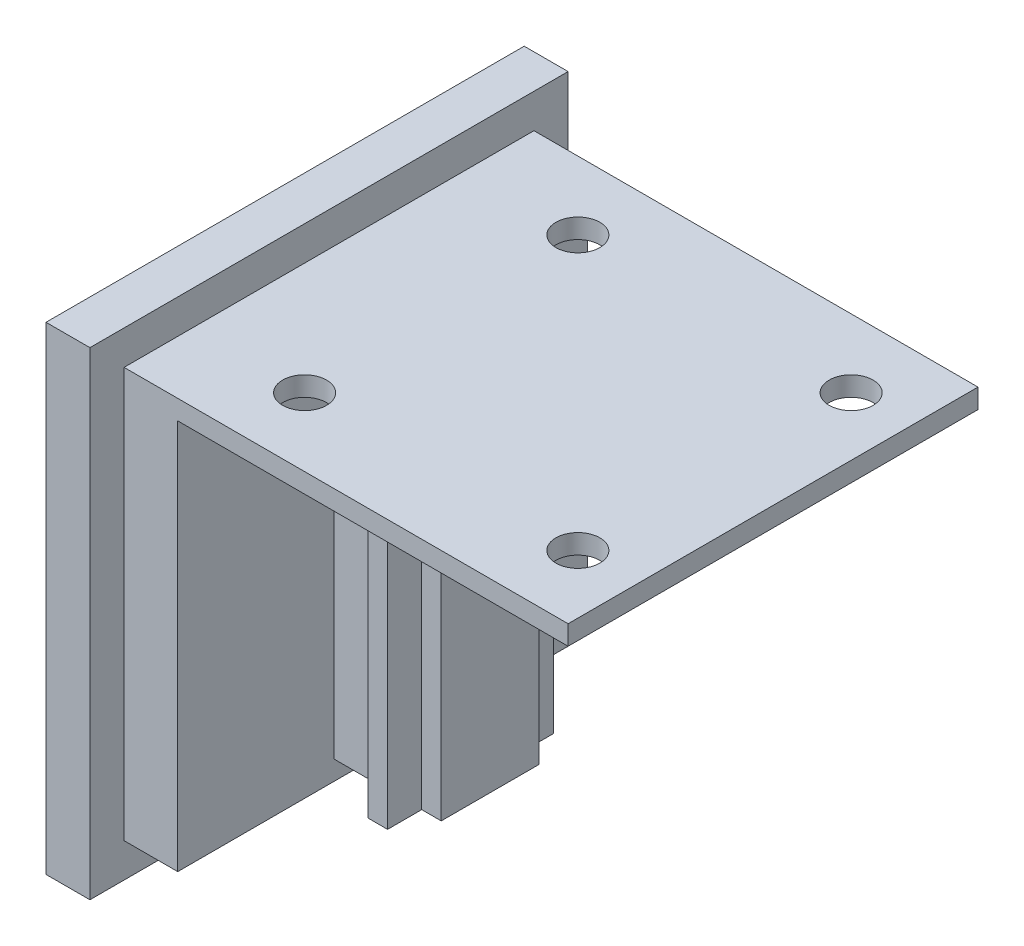
from build123d import *

# Parameters (mm, degrees)
SKETCH1_W                  = 49
SKETCH1_H                  = 49
BOSS_EXTRUDE1_DEPTH        = 4.5
SKETCH3_W                  = 42
SKETCH3_H                  = 42
BOSS_EXTRUDE3_DEPTH        = 5.5
SKETCH4_W                  = 42
SKETCH4_H                  = 2
BOSS_EXTRUDE4_DEPTH        = 40
SKETCH5_W                  = 10
SKETCH5_H                  = 38
BOSS_EXTRUDE5_DEPTH        = 11
SKETCH6_W                  = 2
SKETCH6_H                  = 38
BOSS_EXTRUDE6_DEPTH        = 3.5
SKETCH7_W                  = 2
SKETCH7_H                  = 38
BOSS_EXTRUDE7_DEPTH        = 3.5
F_4_5_4_5_DIAMETER_SLOT1_D = 4.5


with BuildPart() as part:
    # Sketch1 → Boss-Extrude1 (new body)
    with BuildSketch(Plane(origin=(0, 0, 0), x_dir=(0, 0, -1), z_dir=(1, 0, 0))):
        Rectangle(SKETCH1_W, SKETCH1_H)
    extrude(amount=BOSS_EXTRUDE1_DEPTH)

    # Sketch3 → Boss-Extrude3 (add)
    with BuildSketch(Plane(origin=(4.5, 0, 0), x_dir=(0, 0, -1), z_dir=(1, 0, 0))):
        Rectangle(SKETCH3_W, SKETCH3_H)
    extrude(amount=BOSS_EXTRUDE3_DEPTH)

    # Sketch4 → Boss-Extrude4 (add)
    with BuildSketch(Plane(origin=(10, 0, 0), x_dir=(0, 0, -1), z_dir=(1, 0, 0))):
        with Locations((0, 20)):
            Rectangle(SKETCH4_W, SKETCH4_H)
    extrude(amount=BOSS_EXTRUDE4_DEPTH)

    # Sketch5 → Boss-Extrude5 (add)
    with BuildSketch(Plane(origin=(10, 0, 0), x_dir=(0, 0, -1), z_dir=(1, 0, 0))):
        Rectangle(SKETCH5_W, SKETCH5_H)
    extrude(amount=BOSS_EXTRUDE5_DEPTH)

    # Sketch6 → Boss-Extrude6 (add)
    with BuildSketch(Plane.XY.offset(5)):
        with Locations((18, 0)):
            Rectangle(SKETCH6_W, SKETCH6_H)
    extrude(amount=BOSS_EXTRUDE6_DEPTH)

    # Sketch7 → Boss-Extrude7 (add)
    with BuildSketch(Plane(origin=(0, 0, -5), x_dir=(-1, 0, 0), z_dir=(0, 0, -1))):
        with Locations((-18, 0)):
            Rectangle(SKETCH7_W, SKETCH7_H)
    extrude(amount=BOSS_EXTRUDE7_DEPTH)

    # Ø4.5 (4.5) Diameter Slot1 (through all)
    with Locations(Plane(origin=(0, 19, 0), x_dir=(-1, 0, 0), z_dir=(0, -1, 0))):
        with Locations((-44, 14), (-44, -14), (-16, -14), (-16, 14)):
            Hole(F_4_5_4_5_DIAMETER_SLOT1_D / 2)


solid = part.part
